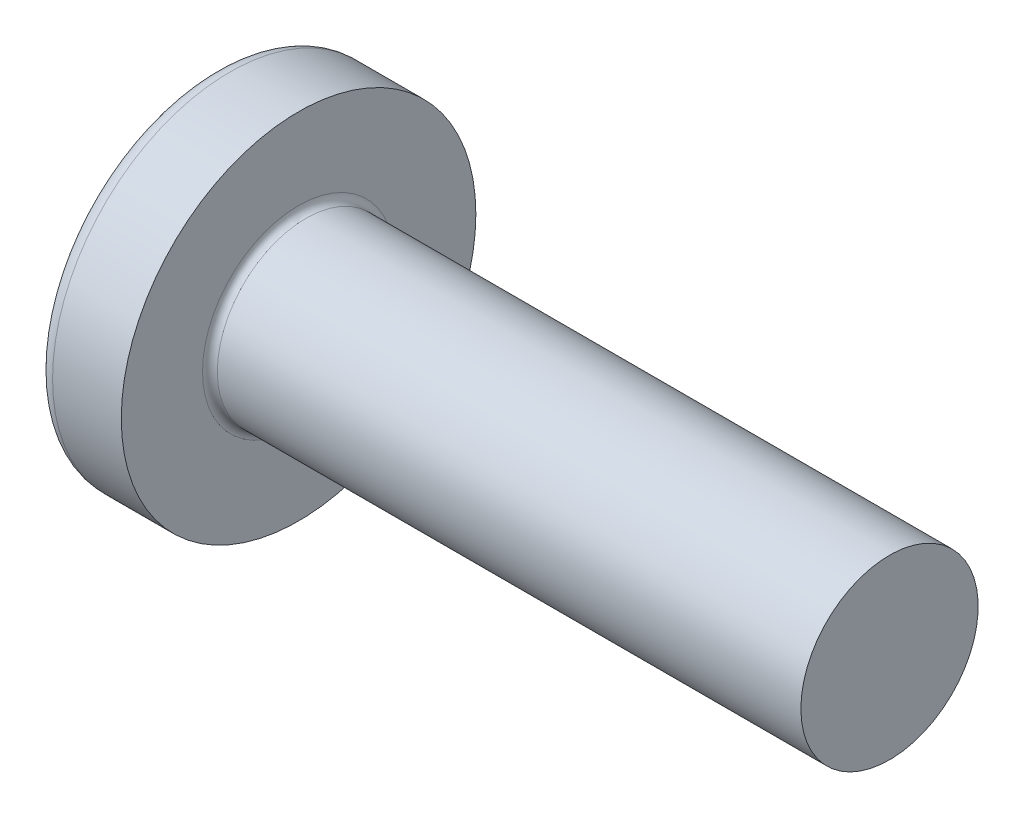
from build123d import *

# Parameters (mm, degrees)
FILLET1_R    = 0.25
SKETCH3_W    = 1.42
SKETCH3_H    = 6.7
SKETCH4_W    = 1.42
SKETCH4_H    = 3.24981585
RECPAT_COUNT = 2
RECPAT_ANGLE = 90


with BuildPart() as part:
    # BodySke → Base-Revolve (revolve)
    with BuildSketch(Plane.XY):
        with BuildLine():
            Line((4.6, 3), (4.6, 6))
            Line((4.6, 6), (2.274716834, 6))
            ThreePointArc((2.274716834, 6), (2.026424569, 5.939532013), (1.833738725, 5.77167019))
            ThreePointArc((1.833738725, 5.77167019), (0.469454036, 3.027985077), (0, 0))
            Line((0, 0), (24.6, 0))
            Line((24.6, 0), (24.6, 3))
            Line((24.6, 3), (4.6, 3))
        make_face()
    revolve(axis=Axis((-25.4, 0, 0), (1, 0, 0)))

    # Fillet1
    fillet1_edges = [part.edges().sort_by_distance(p)[0] for p in [
        (4.6, -3, 0),
    ]]
    fillet(fillet1_edges, radius=FILLET1_R)

    # Sketch3 → Recess section 0
    with BuildSketch(Plane(origin=(0, 0, 0), x_dir=(0, 0, -1), z_dir=(1, 0, 0))):
        Rectangle(SKETCH3_W, SKETCH3_H)
    # Sketch4 → Recess section 1
    with BuildSketch(Plane(origin=(3.46, 0, 0), x_dir=(0, 0, -1), z_dir=(1, 0, 0))):
        Rectangle(SKETCH4_W, SKETCH4_H)
    recess = loft(mode=Mode.SUBTRACT)

    # RecPat: Recess ×2 about axis
    recpat_axis = Axis((0, 0, 0), (1, 0, 0))
    for i in range(1, RECPAT_COUNT):
        add(recess.rotate(recpat_axis, i * RECPAT_ANGLE / (RECPAT_COUNT - 1)), mode=Mode.SUBTRACT)

    # RecCorSke → RecessCore (revolve, cut)
    with BuildSketch(Plane.XY):
        Polygon((0, 0), (0, 1.522446769), (3.46, 1.2805), (3.876059671, 0), align=None)
    revolve(axis=Axis((-3.175, 0, 0), (1, 0, 0)), mode=Mode.SUBTRACT)


solid = part.part
